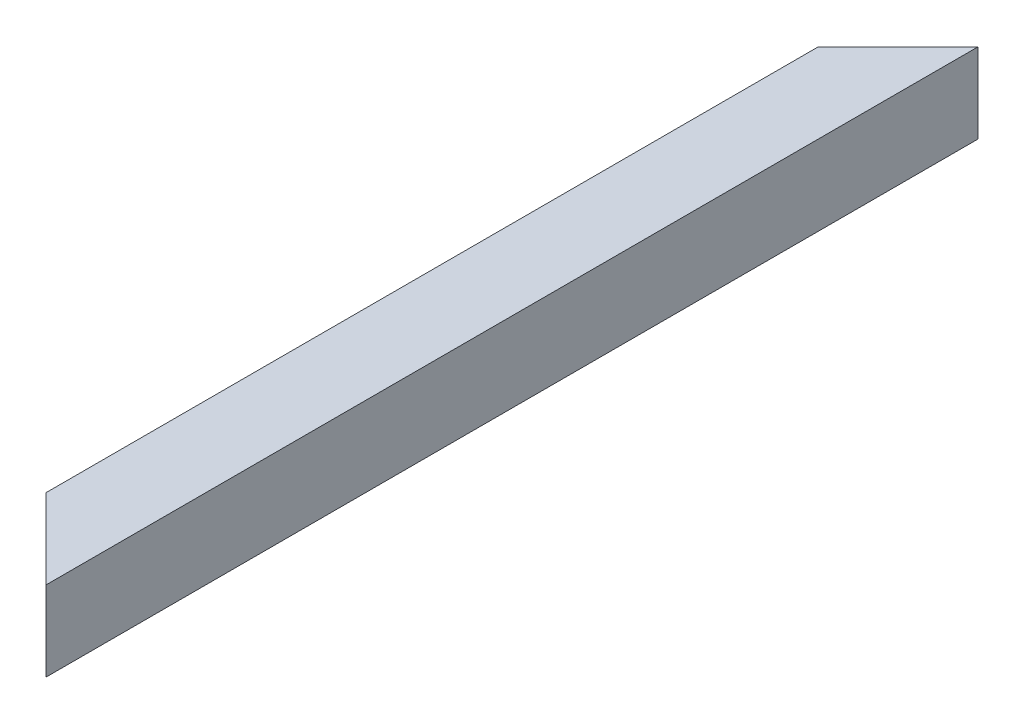
from build123d import *

# Parameters (mm, degrees)
SKETCH1_W          = 60
SKETCH1_H          = 60
SKETCH1_W_2        = 52
SKETCH1_H_2        = 52
CUT_EXTRUDE1_DEPTH = 61.0000001


with BuildPart() as part:
    # Sweep1: sweep along a curve in space
    with BuildLine() as sweep1_path:
        add(Edge.make_bspline(
            [(0, 0, 0), (0, 0, 700)],
            knots=[0, 0, 1, 1], degree=1))
    # Sketch1 → Sweep1 (sweep)
    with BuildSketch(Plane.XY):
        Rectangle(SKETCH1_W, SKETCH1_H)
        Rectangle(SKETCH1_W_2, SKETCH1_H_2, mode=Mode.SUBTRACT)
    sweep(path=sweep1_path.line)

    # Sketch2 → Cut-Extrude1 (cut, through all)
    with BuildSketch(Plane(origin=(0, 30, 0), x_dir=(1, 0, 0), z_dir=(0, 1, 0))):
        Polygon((30, 0), (-30, -60), (-30, 0), align=None)
        Polygon((30, -700), (-30, -640), (-30, -700), align=None)
    extrude(amount=-CUT_EXTRUDE1_DEPTH, mode=Mode.SUBTRACT)


solid = part.part
